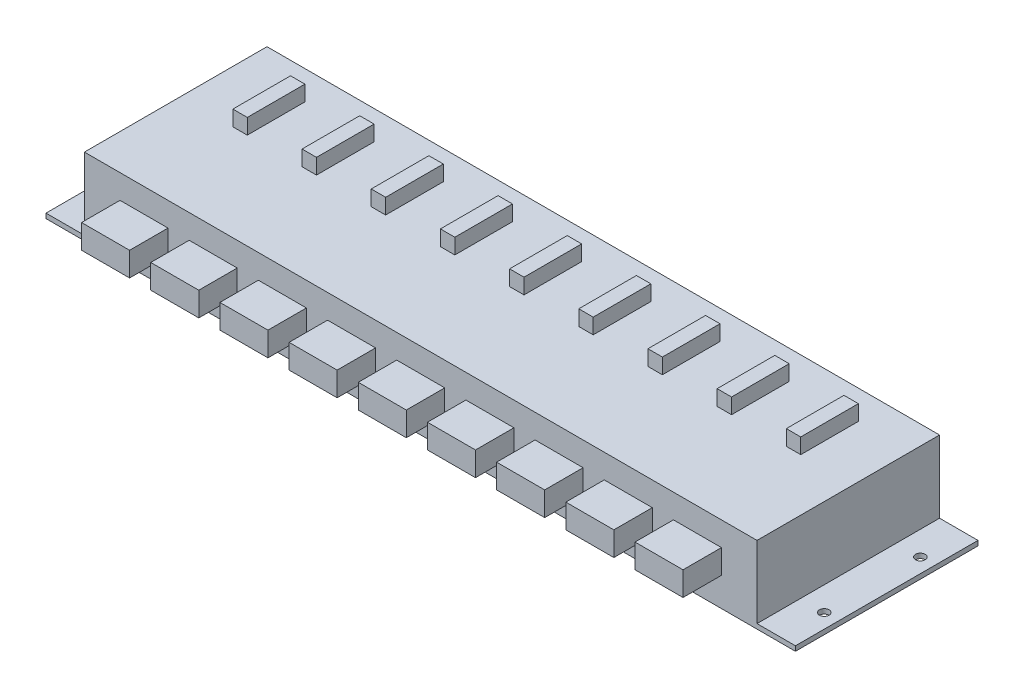
from build123d import *

# Parameters (mm, degrees)
SKETCH1_W           = 222.25
SKETCH1_H           = 60.325
BOSS_EXTRUDE1_DEPTH = 25.4
SKETCH2_W           = 12.7
SKETCH2_H           = 60.325
BOSS_EXTRUDE2_DEPTH = 1.5875
SKETCH3_R           = 1.5875
CUT_EXTRUDE1_DEPTH  = 2.5875
SKETCH4_W           = 4.7625
SKETCH4_H           = 19.05
BOSS_EXTRUDE3_DEPTH = 5.08
SKETCH5_W           = 15.875
SKETCH5_H           = 7.9375
BOSS_EXTRUDE4_DEPTH = 12.7
LPATTERN1_COUNT     = 5
LPATTERN1_PITCH     = 22.86
LPATTERN1_COL_COUNT = 5
LPATTERN1_COL_PITCH = 22.86


with BuildPart() as part:
    # Sketch1 → Boss-Extrude1 (new body)
    with BuildSketch(Plane(origin=(0, 0, 0), x_dir=(1, 0, 0), z_dir=(0, 1, 0))):
        with Locations((111.125, 30.1625)):
            Rectangle(SKETCH1_W, SKETCH1_H)
    extrude(amount=BOSS_EXTRUDE1_DEPTH)

    # Sketch2 → Boss-Extrude2 (add)
    with BuildSketch(Plane.XZ):
        with Locations((228.6, -30.1625)):
            Rectangle(SKETCH2_W, SKETCH2_H)
        with Locations((-6.35, -30.1625)):
            Rectangle(SKETCH2_W, SKETCH2_H)
    extrude(amount=-BOSS_EXTRUDE2_DEPTH)

    # Sketch3 → Cut-Extrude1 (cut, through all)
    with BuildSketch(Plane(origin=(0, 1.5875, 0), x_dir=(1, 0, 0), z_dir=(0, 1, 0))):
        with Locations((-7.9375, 46.0375)):
            Circle(SKETCH3_R)
        with Locations((-7.9375, 14.2875)):
            Circle(SKETCH3_R)
        with Locations((230.1875, 14.2875)):
            Circle(SKETCH3_R)
        with Locations((230.1875, 46.0375)):
            Circle(SKETCH3_R)
    extrude(amount=-CUT_EXTRUDE1_DEPTH, mode=Mode.SUBTRACT)

    # Sketch4 → Boss-Extrude3 (add)
    with BuildSketch(Plane(origin=(0, 25.4, 0), x_dir=(1, 0, 0), z_dir=(0, 1, 0))):
        with Locations((111.125, 41.275)):
            Rectangle(SKETCH4_W, SKETCH4_H)
    boss_extrude3 = extrude(amount=BOSS_EXTRUDE3_DEPTH)

    # Sketch5 → Boss-Extrude4 (add)
    with BuildSketch(Plane.XY):
        with Locations((111.125, 13.49375)):
            Rectangle(SKETCH5_W, SKETCH5_H)
    boss_extrude4 = extrude(amount=BOSS_EXTRUDE4_DEPTH)

    # LPattern1: Boss-Extrude3, Boss-Extrude4 ×5
    with Locations(*[(i * LPATTERN1_PITCH, 0, 0) for i in range(1, LPATTERN1_COUNT)]):
        add(boss_extrude3)
        add(boss_extrude4)

    # LPattern1 col: Boss-Extrude3, Boss-Extrude4 ×5
    with Locations(*[(-i * LPATTERN1_COL_PITCH, 0, 0) for i in range(1, LPATTERN1_COL_COUNT)]):
        add(boss_extrude3)
        add(boss_extrude4)


solid = part.part
